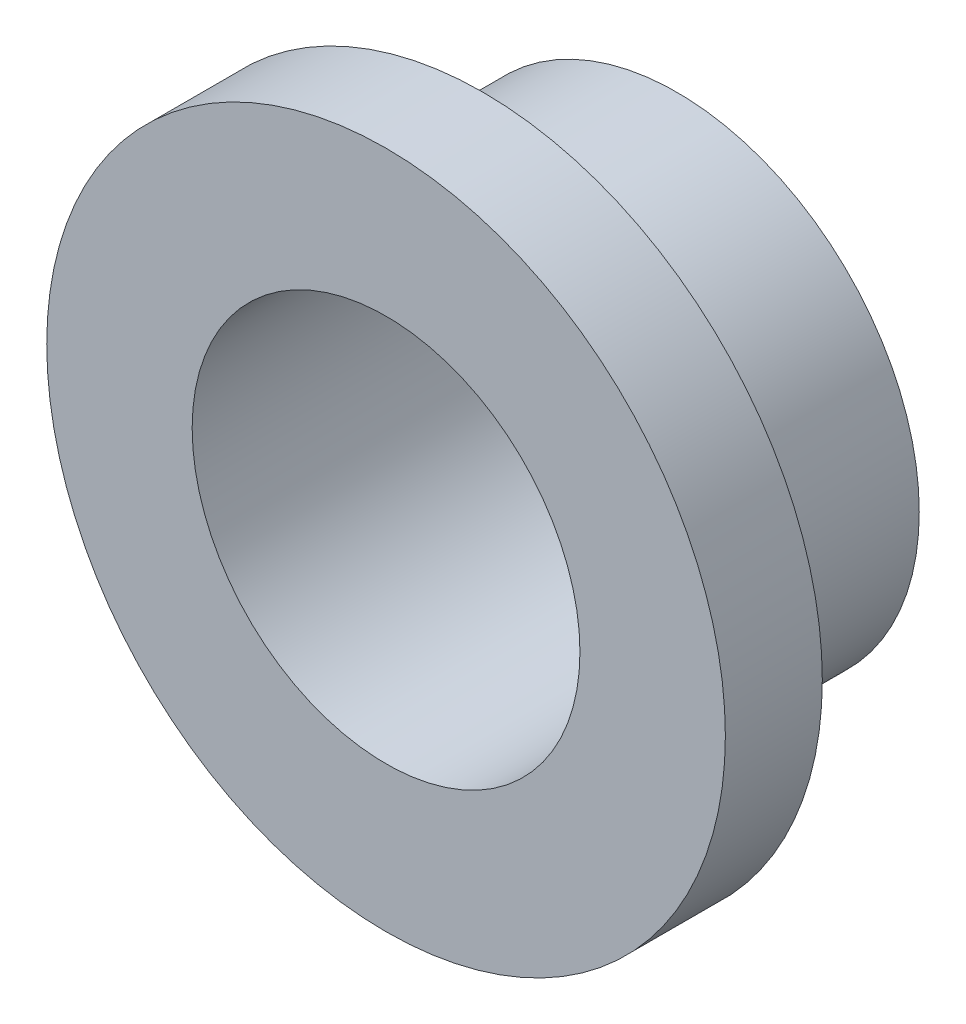
from build123d import *

# Parameters (mm, degrees)
SKETCH1_R           = 7.9375
SKETCH1_R_2         = 6.35
BOSS_EXTRUDE1_DEPTH = 9.525
SKETCH2_R           = 11.1125
SKETCH2_R_2         = 6.35
BOSS_EXTRUDE2_DEPTH = 3.175


with BuildPart() as part:
    # Sketch1 → Boss-Extrude1 (new body)
    with BuildSketch(Plane.XY):
        Circle(SKETCH1_R)
        Circle(SKETCH1_R_2, mode=Mode.SUBTRACT)
    extrude(amount=BOSS_EXTRUDE1_DEPTH)

    # Sketch2 → Boss-Extrude2 (add)
    with BuildSketch(Plane.XY.offset(9.525)):
        Circle(SKETCH2_R)
        Circle(SKETCH2_R_2, mode=Mode.SUBTRACT)
    extrude(amount=-BOSS_EXTRUDE2_DEPTH)


solid = part.part
